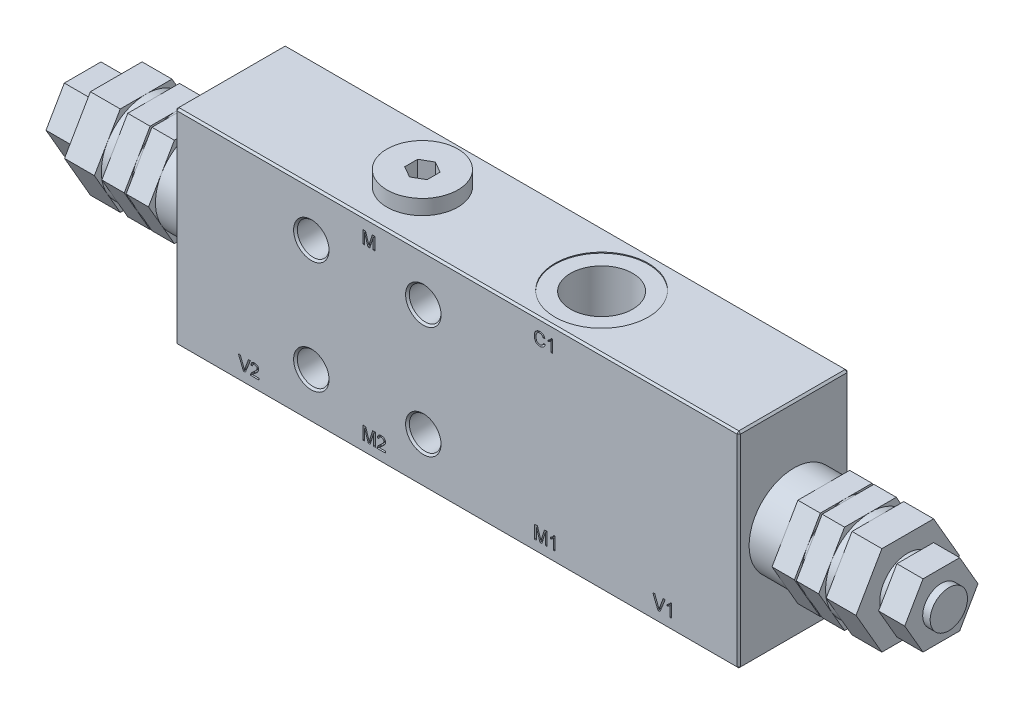
from build123d import *

# Parameters (mm, degrees)
SKETCH1_W            = 151
SKETCH1_H            = 55
SKETCH1_R            = 4.25
BASE_EXTRUDE_DEPTH   = 29.5
CHAMFER1_SIZE        = 0.5
SKETCH5_R            = 4.5
CUT_EXTRUDE4_DEPTH   = 20
HOLE1_D              = 16.662
HOLE1_DEPTH          = 20
HOLE1_CBORE_D        = 25
HOLE1_CBORE_DEPTH    = 0.25
SKETCH8_R            = 9.5
BOSS_EXTRUDE1_DEPTH  = 4
CUT_EXTRUDE5_DEPTH   = 10
HOLE2_D              = 16.662
HOLE2_DEPTH          = 20
HOLE2_CBORE_D        = 25
HOLE2_CBORE_DEPTH    = 0.25
LPATTERN1_COUNT      = 2
LPATTERN1_PITCH      = 111
SKETCH13_R           = 9.5
BOSS_EXTRUDE2_DEPTH  = 4
CUT_EXTRUDE6_DEPTH   = 10
SKETCH43_R           = 9.5
EXTRUDE1_DEPTH       = 4
CUT_EXTRUDE13_DEPTH  = 10
SKETCH15_R           = 12
BOSS_EXTRUDE3_DEPTH  = 8
BOSS_EXTRUDE4_DEPTH  = 6
SKETCH17_R           = 12
BOSS_EXTRUDE5_DEPTH  = 0.5
BOSS_EXTRUDE6_DEPTH  = 6
SKETCH19_R           = 12
BOSS_EXTRUDE7_DEPTH  = 2
BOSS_EXTRUDE8_DEPTH  = 8
SKETCH21_R           = 7.5
BOSS_EXTRUDE9_DEPTH  = 2
BOSS_EXTRUDE10_DEPTH = 7
SKETCH23_R           = 5
BOSS_EXTRUDE11_DEPTH = 2
SKETCH24_R           = 12
BOSS_EXTRUDE12_DEPTH = 8
BOSS_EXTRUDE13_DEPTH = 6
SKETCH26_R           = 12
BOSS_EXTRUDE14_DEPTH = 0.5
BOSS_EXTRUDE15_DEPTH = 6
SKETCH28_R           = 12
BOSS_EXTRUDE16_DEPTH = 2
BOSS_EXTRUDE17_DEPTH = 8
SKETCH30_R           = 7.5
BOSS_EXTRUDE18_DEPTH = 2
BOSS_EXTRUDE19_DEPTH = 7
SKETCH32_R           = 5
BOSS_EXTRUDE20_DEPTH = 2
CUT_EXTRUDE7_DEPTH   = 1
CUT_EXTRUDE8_DEPTH   = 1
CUT_EXTRUDE9_DEPTH   = 1
CUT_EXTRUDE10_DEPTH  = 1
CUT_EXTRUDE11_DEPTH  = 1
CUT_EXTRUDE12_DEPTH  = 1


with BuildPart() as part:
    # Sketch1 → Base-Extrude (new body)
    with BuildSketch(Plane.XY):
        with Locations((75.5, 27.5)):
            Rectangle(SKETCH1_W, SKETCH1_H)
        with Locations((36.5, 42.5)):
            Circle(SKETCH1_R, mode=Mode.SUBTRACT)
        with Locations((66.5, 42.5)):
            Circle(SKETCH1_R, mode=Mode.SUBTRACT)
        with Locations((36.5, 12.5)):
            Circle(SKETCH1_R, mode=Mode.SUBTRACT)
        with Locations((66.5, 12.5)):
            Circle(SKETCH1_R, mode=Mode.SUBTRACT)
    extrude(amount=-BASE_EXTRUDE_DEPTH)

    # Chamfer1
    chamfer1_edges = [part.edges().sort_by_distance(p)[0] for p in [
        (151, 27.5, -29.5),
        (32.25, 42.5, -29.5),
        (32.25, 42.5, 0),
        (75.5, 0, -29.5),
        (62.25, 42.5, -29.5),
        (62.25, 42.5, 0),
        (32.25, 12.5, -29.5),
        (32.25, 12.5, 0),
        (62.25, 12.5, -29.5),
        (62.25, 12.5, 0),
        (0, 27.5, -29.5),
        (75.5, 0, 0),
        (151, 27.5, 0),
        (75.5, 55, 0),
        (0, 27.5, 0),
        (75.5, 55, -29.5),
        (0, 0, -14.75),
        (151, 0, -14.75),
        (151, 55, -14.75),
        (0, 55, -14.75),
    ]]
    chamfer(chamfer1_edges, length=CHAMFER1_SIZE)

    # Sketch5 → Cut-Extrude4 (cut)
    with BuildSketch(Plane(origin=(0, 0, -29.5), x_dir=(-1, 0, 0), z_dir=(0, 0, -1))):
        with Locations((-51.5, 27.5)):
            Circle(SKETCH5_R)
    extrude(amount=-CUT_EXTRUDE4_DEPTH, mode=Mode.SUBTRACT)

    # Hole1
    with Locations(Plane(origin=(0, 55, 0), x_dir=(-1, 0, 0), z_dir=(0, 1, 0))):
        with Locations((-99.5, -14.75)):
            CounterBoreHole(HOLE1_D / 2, HOLE1_CBORE_D / 2, HOLE1_CBORE_DEPTH, depth=HOLE1_DEPTH)

    # Sketch8 → Boss-Extrude1 (add)
    with BuildSketch(Plane(origin=(0, 55, 0), x_dir=(-1, 0, 0), z_dir=(0, 1, 0))):
        with Locations((-51.5, -14.75)):
            Circle(SKETCH8_R)
    extrude(amount=BOSS_EXTRUDE1_DEPTH)

    # Sketch9 → Cut-Extrude5 (cut)
    with BuildSketch(Plane(origin=(0, 59, 0), x_dir=(-1, 0, 0), z_dir=(0, 1, 0))):
        Polygon((-51.5, -18.214101615), (-48.5, -16.482050808), (-48.5, -13.017949192), (-51.5, -11.285898385), (-54.5, -13.017949192), (-54.5, -16.482050808), align=None)
    extrude(amount=-CUT_EXTRUDE5_DEPTH, mode=Mode.SUBTRACT)

    # Hole2
    with Locations(Plane.XZ):
        with Locations((131, -14.75)):
            hole2 = CounterBoreHole(HOLE2_D / 2, HOLE2_CBORE_D / 2, HOLE2_CBORE_DEPTH, depth=HOLE2_DEPTH)

    # LPattern1: Hole2 ×2
    with Locations(*[(-i * LPATTERN1_PITCH, 0, 0) for i in range(1, LPATTERN1_COUNT)]):
        add(hole2, mode=Mode.SUBTRACT)

    # Sketch13 → Boss-Extrude2 (add)
    with BuildSketch(Plane.XZ):
        with Locations(Location((98, -14.75, 0), (0, 0, 270))):
            Circle(SKETCH13_R)
    extrude(amount=BOSS_EXTRUDE2_DEPTH)

    # Sketch14 → Cut-Extrude6 (cut)
    with BuildSketch(Plane.XZ.offset(4)):
        Polygon((98, -11.285898385), (95, -13.017949192), (95, -16.482050808), (98, -18.214101615), (101, -16.482050808), (101, -13.017949192), align=None)
    extrude(amount=-CUT_EXTRUDE6_DEPTH, mode=Mode.SUBTRACT)

    # Sketch43 → Extrude1 (add)
    with BuildSketch(Plane.XZ):
        with Locations(Location((52, -14.75, 0), (0, 0, 270))):
            Circle(SKETCH43_R)
    extrude(amount=EXTRUDE1_DEPTH)

    # Sketch44 → Cut-Extrude13 (cut)
    with BuildSketch(Plane.XZ.offset(4)):
        Polygon((49, -13.017949192), (49, -16.482050808), (52, -18.214101615), (55, -16.482050808), (55, -13.017949192), (52, -11.285898385), align=None)
    extrude(amount=-CUT_EXTRUDE13_DEPTH, mode=Mode.SUBTRACT)

    # Sketch15 → Boss-Extrude3 (add)
    with BuildSketch(Plane(origin=(151, 0, 0), x_dir=(0, 0, -1), z_dir=(1, 0, 0))):
        with Locations(Location((14.75, 27.5, 0), (0, 0, 180))):
            Circle(SKETCH15_R)
    extrude(amount=BOSS_EXTRUDE3_DEPTH)

    # Sketch16 → Boss-Extrude4 (add)
    with BuildSketch(Plane(origin=(159, 0, 0), x_dir=(0, 0, -1), z_dir=(1, 0, 0))):
        Polygon((21.67820323, 39.5), (7.82179677, 39.5), (0.893593539, 27.5), (7.82179677, 15.5), (21.67820323, 15.5), (28.606406461, 27.5), align=None)
    extrude(amount=BOSS_EXTRUDE4_DEPTH)

    # Sketch17 → Boss-Extrude5 (add)
    with BuildSketch(Plane(origin=(165, 0, 0), x_dir=(0, 0, -1), z_dir=(1, 0, 0))):
        with Locations(Location((14.75, 27.5, 0), (0, 0, 180))):
            Circle(SKETCH17_R)
    extrude(amount=BOSS_EXTRUDE5_DEPTH)

    # Sketch18 → Boss-Extrude6 (add)
    with BuildSketch(Plane(origin=(165.5, 0, 0), x_dir=(0, 0, -1), z_dir=(1, 0, 0))):
        Polygon((0.893593539, 27.5), (7.82179677, 15.5), (21.67820323, 15.5), (28.606406461, 27.5), (21.67820323, 39.5), (7.82179677, 39.5), align=None)
    extrude(amount=BOSS_EXTRUDE6_DEPTH)

    # Sketch19 → Boss-Extrude7 (add)
    with BuildSketch(Plane(origin=(171.5, 0, 0), x_dir=(0, 0, -1), z_dir=(1, 0, 0))):
        with Locations(Location((14.75, 27.5, 0), (0, 0, 180))):
            Circle(SKETCH19_R)
    extrude(amount=BOSS_EXTRUDE7_DEPTH)

    # Sketch20 → Boss-Extrude8 (add)
    with BuildSketch(Plane(origin=(173.5, 0, 0), x_dir=(0, 0, -1), z_dir=(1, 0, 0))):
        Polygon((0.893593539, 27.5), (7.82179677, 15.5), (21.67820323, 15.5), (28.606406461, 27.5), (21.67820323, 39.5), (7.82179677, 39.5), align=None)
    extrude(amount=BOSS_EXTRUDE8_DEPTH)

    # Sketch21 → Boss-Extrude9 (add)
    with BuildSketch(Plane(origin=(181.5, 0, 0), x_dir=(0, 0, -1), z_dir=(1, 0, 0))):
        with Locations(Location((14.75, 27.5, 0), (0, 0, 180))):
            Circle(SKETCH21_R)
    extrude(amount=BOSS_EXTRUDE9_DEPTH)

    # Sketch22 → Boss-Extrude10 (add)
    with BuildSketch(Plane(origin=(183.5, 0, 0), x_dir=(0, 0, -1), z_dir=(1, 0, 0))):
        Polygon((4.935045424, 27.5), (9.842522712, 19), (19.657477288, 19), (24.564954576, 27.5), (19.657477288, 36), (9.842522712, 36), align=None)
    extrude(amount=BOSS_EXTRUDE10_DEPTH)

    # Sketch23 → Boss-Extrude11 (add)
    with BuildSketch(Plane(origin=(190.5, 0, 0), x_dir=(0, 0, -1), z_dir=(1, 0, 0))):
        with Locations((14.75, 27.5)):
            Circle(SKETCH23_R)
    extrude(amount=BOSS_EXTRUDE11_DEPTH)

    # Sketch24 → Boss-Extrude12 (add)
    with BuildSketch(Plane.ZY):
        with Locations((-14.75, 27.5)):
            Circle(SKETCH24_R)
    extrude(amount=BOSS_EXTRUDE12_DEPTH)

    # Sketch25 → Boss-Extrude13 (add)
    with BuildSketch(Plane.ZY.offset(8)):
        Polygon((-0.893593539, 27.5), (-7.82179677, 39.5), (-21.67820323, 39.5), (-28.606406461, 27.5), (-21.67820323, 15.5), (-7.82179677, 15.5), align=None)
    extrude(amount=BOSS_EXTRUDE13_DEPTH)

    # Sketch26 → Boss-Extrude14 (add)
    with BuildSketch(Plane.ZY.offset(14)):
        with Locations((-14.75, 27.5)):
            Circle(SKETCH26_R)
    extrude(amount=BOSS_EXTRUDE14_DEPTH)

    # Sketch27 → Boss-Extrude15 (add)
    with BuildSketch(Plane.ZY.offset(14.5)):
        Polygon((-0.893593539, 27.5), (-7.82179677, 39.5), (-21.67820323, 39.5), (-28.606406461, 27.5), (-21.67820323, 15.5), (-7.82179677, 15.5), align=None)
    extrude(amount=BOSS_EXTRUDE15_DEPTH)

    # Sketch28 → Boss-Extrude16 (add)
    with BuildSketch(Plane.ZY.offset(20.5)):
        with Locations((-14.75, 27.5)):
            Circle(SKETCH28_R)
    extrude(amount=BOSS_EXTRUDE16_DEPTH)

    # Sketch29 → Boss-Extrude17 (add)
    with BuildSketch(Plane.ZY.offset(22.5)):
        Polygon((-0.893593539, 27.5), (-7.82179677, 39.5), (-21.67820323, 39.5), (-28.606406461, 27.5), (-21.67820323, 15.5), (-7.82179677, 15.5), align=None)
    extrude(amount=BOSS_EXTRUDE17_DEPTH)

    # Sketch30 → Boss-Extrude18 (add)
    with BuildSketch(Plane.ZY.offset(30.5)):
        with Locations((-14.75, 27.5)):
            Circle(SKETCH30_R)
    extrude(amount=BOSS_EXTRUDE18_DEPTH)

    # Sketch31 → Boss-Extrude19 (add)
    with BuildSketch(Plane.ZY.offset(32.5)):
        Polygon((-4.935045424, 27.5), (-9.842522712, 36), (-19.657477288, 36), (-24.564954576, 27.5), (-19.657477288, 19), (-9.842522712, 19), align=None)
    extrude(amount=BOSS_EXTRUDE19_DEPTH)

    # Sketch32 → Boss-Extrude20 (add)
    with BuildSketch(Plane.ZY.offset(39.5)):
        with Locations(Location((-14.75, 27.5, 0), (0, 0, 180))):
            Circle(SKETCH32_R)
    extrude(amount=BOSS_EXTRUDE20_DEPTH)

    # Sketch33 → Cut-Extrude7 (cut)
    with BuildSketch(Plane.XY):
        with BuildLine():
            Line((129.353624939, 3), (127.959128008, 6.458186129))
            Line((127.959128008, 6.458186129), (128.487692916, 6.458186129))
            Line((128.487692916, 6.458186129), (129.428441466, 3.979542305))
            add(Edge.make_bspline(
                [(129.428441466, 3.979542305), (129.446850982, 3.930649992), (129.482863794, 3.835006544), (129.533083688, 3.693078224), (129.57797725, 3.555826305), (129.60504301, 3.465350458), (129.618253765, 3.421189336)],
                knots=[0, 0, 0, 0, 1.062747156, 2.078952616, 3.062339733, 4, 4, 4, 4], degree=3))
            add(Edge.make_bspline(
                [(129.618253765, 3.421189336), (129.646377518, 3.514574668), (129.703028249, 3.702684252), (129.7715055, 3.88681941), (129.805987828, 3.979542305)],
                knots=[0, 0, 0, 0, 0.992882236, 2, 2, 2, 2], degree=3))
            Line((129.805987828, 3.979542305), (130.748814615, 6.458186129))
            Line((130.748814615, 6.458186129), (131.277379522, 6.458186129))
            Line((131.277379522, 6.458186129), (129.882189846, 3))
            Line((129.882189846, 3), (129.353624939, 3))
        make_face()
        with BuildLine():
            Line((132.965600595, 3), (132.522243399, 3))
            Line((132.522243399, 3), (132.522243399, 5.694780457))
            add(Edge.make_bspline(
                [(132.522243399, 5.694780457), (132.496714852, 5.670161314), (132.443656566, 5.618993125), (132.353967138, 5.54657736), (132.253862274, 5.473180912), (132.1446419, 5.402602023), (132.033310205, 5.336159609), (131.925722455, 5.276404874), (131.823674874, 5.225837869), (131.756455581, 5.198187631), (131.724200446, 5.184919681)],
                knots=[0, 0, 0, 0, 0.893362401, 1.856755847, 2.901947673, 4.020460078, 5.132200827, 6.168787962, 7.121294059, 8, 8, 8, 8], degree=3))
            Line((131.724200446, 5.184919681), (131.724200446, 5.593639596))
            add(Edge.make_bspline(
                [(131.724200446, 5.593639596), (131.779601974, 5.622171494), (131.888795105, 5.678406175), (132.043061388, 5.775531201), (132.187085558, 5.880818726), (132.318483444, 5.994245441), (132.436273276, 6.110187905), (132.535536478, 6.227178406), (132.618593609, 6.340928576), (132.660264945, 6.420256706), (132.6801894, 6.458186129)],
                knots=[0, 0, 0, 0, 1.141258006, 2.249351951, 3.335817539, 4.406819942, 5.426913362, 6.360259544, 7.215985427, 8, 8, 8, 8], degree=3))
            Line((132.6801894, 6.458186129), (132.965600595, 6.458186129))
            Line((132.965600595, 6.458186129), (132.965600595, 3))
        make_face()
    extrude(amount=-CUT_EXTRUDE7_DEPTH, mode=Mode.SUBTRACT)

    # Sketch34 → Cut-Extrude8 (cut)
    with BuildSketch(Plane.XY):
        with BuildLine():
            Line((18.31643864, 3), (16.960250829, 6.36318408))
            Line((16.960250829, 6.36318408), (17.474295191, 6.36318408))
            Line((17.474295191, 6.36318408), (18.389199834, 3.95263267))
            add(Edge.make_bspline(
                [(18.389199834, 3.95263267), (18.407103611, 3.905083509), (18.442127091, 3.812067544), (18.490967363, 3.674038228), (18.534627625, 3.540556844), (18.560949844, 3.452566517), (18.573797678, 3.409618574)],
                knots=[0, 0, 0, 0, 1.062747156, 2.078952616, 3.062339733, 4, 4, 4, 4], degree=3))
            add(Edge.make_bspline(
                [(18.573797678, 3.409618574), (18.601148825, 3.500438458), (18.656243268, 3.683380363), (18.722839336, 3.862457026), (18.756374378, 3.95263267)],
                knots=[0, 0, 0, 0, 0.992882236, 2, 2, 2, 2], degree=3))
            Line((18.756374378, 3.95263267), (19.673300166, 6.36318408))
            Line((19.673300166, 6.36318408), (20.187344527, 6.36318408))
            Line((20.187344527, 6.36318408), (18.830483002, 3))
            Line((18.830483002, 3), (18.31643864, 3))
        make_face()
        with BuildLine():
            Line((22.432835821, 3.431177446), (22.432835821, 3))
            Line((22.432835821, 3), (20.233830846, 3))
            add(Edge.make_bspline(
                [(20.233830846, 3), (20.233785826, 3.025626088), (20.233695938, 3.076792371), (20.242354098, 3.152464057), (20.255914509, 3.227131895), (20.27124726, 3.27501341), (20.278969735, 3.299129353)],
                knots=[0, 0, 0, 0, 1.01057331, 2.01775941, 3.001627217, 4, 4, 4, 4], degree=3))
            add(Edge.make_bspline(
                [(20.278969735, 3.299129353), (20.293238298, 3.338531927), (20.322291443, 3.418762057), (20.381153419, 3.534522931), (20.450389012, 3.649583705), (20.517799608, 3.743259421), (20.579533158, 3.818099769), (20.631304786, 3.876653679), (20.68867724, 3.936590507), (20.751604575, 3.997899303), (20.819481151, 4.060977141), (20.892399588, 4.126034381), (20.971220936, 4.191858612), (21.026246486, 4.23548965), (21.054415423, 4.257825456)],
                knots=[0, 0, 0, 0, 1.204657718, 2.452881516, 3.728232997, 5.065887527, 5.768225529, 6.518857853, 7.313994055, 8.154655305, 9.046094665, 9.979688118, 10.965752482, 12, 12, 12, 12], degree=3))
            add(Edge.make_bspline(
                [(21.054415423, 4.257825456), (21.097689869, 4.294248854), (21.181017558, 4.364384418), (21.298689315, 4.468459095), (21.40616331, 4.565098327), (21.501728143, 4.655995915), (21.586165434, 4.740270211), (21.659673443, 4.817730281), (21.722884656, 4.888134386), (21.775027387, 4.954030859), (21.81902181, 5.016255458), (21.856303197, 5.076951712), (21.887372287, 5.137179851), (21.913248682, 5.196749297), (21.933714711, 5.255914796), (21.947665222, 5.314848723), (21.957125975, 5.372966311), (21.958072531, 5.411638399), (21.95854063, 5.430762852)],
                knots=[0, 0, 0, 0, 1.782554561, 3.432421876, 4.950675607, 6.337395053, 7.588547463, 8.709982106, 9.702713005, 10.569305638, 11.356701089, 12.103210377, 12.812277205, 13.490692607, 14.148717897, 14.782152033, 15.397739362, 16, 16, 16, 16], degree=3))
            add(Edge.make_bspline(
                [(21.95854063, 5.430762852), (21.958072475, 5.449664166), (21.95715398, 5.486747515), (21.948439341, 5.541018765), (21.936307866, 5.593283276), (21.916694964, 5.642600171), (21.893349705, 5.690429916), (21.863403776, 5.735261151), (21.828762492, 5.778211187), (21.789101154, 5.818147632), (21.745781684, 5.855614393), (21.69737835, 5.886758373), (21.64707027, 5.914797235), (21.593121857, 5.937342088), (21.535620774, 5.953897176), (21.474985601, 5.965911906), (21.411225962, 5.973529889), (21.36771449, 5.974584823), (21.345460199, 5.975124378)],
                knots=[0, 0, 0, 0, 0.988194508, 1.938783882, 2.870742509, 3.789494954, 4.709148727, 5.651055405, 6.603531303, 7.592354411, 8.592907906, 9.593461401, 10.59787167, 11.603930315, 12.645063138, 13.723588815, 14.835711238, 16, 16, 16, 16], degree=3))
            add(Edge.make_bspline(
                [(21.345460199, 5.975124378), (21.322082685, 5.974587496), (21.276331171, 5.973536777), (21.209454711, 5.965888412), (21.145967104, 5.954202745), (21.086019885, 5.936336359), (21.029686019, 5.913829101), (20.97719494, 5.885498457), (20.927706047, 5.853518284), (20.882777937, 5.815656171), (20.842150036, 5.773674812), (20.806081919, 5.72796981), (20.776529516, 5.677659155), (20.752123923, 5.623849066), (20.732499783, 5.566370382), (20.718253325, 5.504783693), (20.710486061, 5.439266819), (20.708924129, 5.394400883), (20.708126036, 5.371475954)],
                knots=[0, 0, 0, 0, 1.131143733, 2.213731411, 3.253917892, 4.251203413, 5.236093891, 6.184197493, 7.13373276, 8.082770301, 9.020476205, 9.957489029, 10.893177274, 11.836722509, 12.812818608, 13.827831385, 14.890097571, 16, 16, 16, 16], degree=3))
            Line((20.708126036, 5.371475954), (20.27694859, 5.414593698))
            add(Edge.make_bspline(
                [(20.27694859, 5.414593698), (20.281360148, 5.452171866), (20.289942454, 5.525276958), (20.311319808, 5.631157369), (20.341331677, 5.729656501), (20.377243412, 5.82214764), (20.422262155, 5.907056308), (20.47315197, 5.986138745), (20.533174158, 6.056886788), (20.599482751, 6.121530516), (20.672804233, 6.178498651), (20.752449861, 6.228268225), (20.838383203, 6.269897401), (20.930125641, 6.304364624), (21.027887792, 6.330515773), (21.131531356, 6.349268614), (21.24122301, 6.36082808), (21.31646185, 6.362387541), (21.354892206, 6.36318408)],
                knots=[0, 0, 0, 0, 1.130804643, 2.199883102, 3.223565206, 4.205909148, 5.160801384, 6.091796021, 7.01151579, 7.927798993, 8.855738875, 9.7815393, 10.730299821, 11.705391175, 12.706931101, 13.751121791, 14.851322166, 16, 16, 16, 16], degree=3))
            add(Edge.make_bspline(
                [(21.354892206, 6.36318408), (21.393782551, 6.362518127), (21.469541173, 6.361220846), (21.579933661, 6.347947062), (21.684092026, 6.327273264), (21.782398107, 6.29846032), (21.874271099, 6.260677958), (21.959781674, 6.214516443), (22.039324103, 6.160426067), (22.111569395, 6.097757511), (22.176714864, 6.029344284), (22.233805261, 5.956332623), (22.281535582, 5.879034435), (22.322174986, 5.798503348), (22.352318732, 5.713037792), (22.37351637, 5.623799688), (22.387920779, 5.530712779), (22.389111013, 5.467199368), (22.389718076, 5.434805141)],
                knots=[0, 0, 0, 0, 1.195390245, 2.328627238, 3.413424916, 4.457841177, 5.473507151, 6.462241215, 7.441013641, 8.425227782, 9.397253344, 10.342087291, 11.269524934, 12.186751184, 13.110685745, 14.048630397, 15.004728144, 16, 16, 16, 16], degree=3))
            add(Edge.make_bspline(
                [(22.389718076, 5.434805141), (22.3887911, 5.401523743), (22.386935102, 5.334887501), (22.372448787, 5.235285971), (22.347662541, 5.136765339), (22.314802594, 5.038126551), (22.269909068, 4.938978112), (22.213193721, 4.837952268), (22.142832135, 4.734675838), (22.075164017, 4.646879398), (22.012175982, 4.573283842), (21.956343041, 4.512710399), (21.89174756, 4.448355167), (21.820812757, 4.377989374), (21.74064557, 4.304110451), (21.653549388, 4.22450605), (21.557617635, 4.141271055), (21.491022302, 4.084408902), (21.456623134, 4.055037313)],
                knots=[0, 0, 0, 0, 0.927118007, 1.856282007, 2.79721255, 3.754929441, 4.749232485, 5.824981375, 6.979078785, 8.228161913, 8.911614355, 9.677694854, 10.522803217, 11.452009355, 12.461436787, 13.560019032, 14.739651695, 16, 16, 16, 16], degree=3))
            add(Edge.make_bspline(
                [(21.456623134, 4.055037313), (21.427165443, 4.031055612), (21.370994159, 3.9853262), (21.291079627, 3.919031045), (21.219500513, 3.858240185), (21.15458295, 3.804936501), (21.098691194, 3.756541762), (21.049856536, 3.715175445), (21.009853166, 3.678757667), (20.948935116, 3.623438328), (20.871777209, 3.544586202), (20.814923962, 3.467967793), (20.787624378, 3.431177446)],
                knots=[0, 0, 0, 0, 1.241996727, 2.368296581, 3.394949853, 4.3125351, 5.114548721, 5.812230366, 6.404953749, 6.883082049, 8.503329734, 10, 10, 10, 10], degree=3))
            Line((20.787624378, 3.431177446), (22.432835821, 3.431177446))
        make_face()
    extrude(amount=-CUT_EXTRUDE8_DEPTH, mode=Mode.SUBTRACT)

    # Sketch35 → Cut-Extrude9 (cut)
    with BuildSketch(Plane.XY):
        with BuildLine():
            Line((98.673300166, 49.687085406), (99.147595357, 49.576596186))
            add(Edge.make_bspline(
                [(99.147595357, 49.576596186), (99.135712938, 49.532141815), (99.112469453, 49.445183549), (99.066514259, 49.320736644), (99.014935189, 49.203948532), (98.956480703, 49.095126853), (98.89051102, 48.994897265), (98.818774071, 48.901971625), (98.738428457, 48.81829867), (98.652422153, 48.741947272), (98.560085508, 48.674605544), (98.462531784, 48.616454726), (98.360232535, 48.566980183), (98.2527743, 48.526295358), (98.140087413, 48.495676538), (98.022752099, 48.473359749), (97.900426218, 48.459613906), (97.817044703, 48.457804226), (97.774564677, 48.456882255)],
                knots=[0, 0, 0, 0, 1.145254194, 2.240259345, 3.299159039, 4.322497661, 5.312016644, 6.284080175, 7.241264552, 8.196044782, 9.144516039, 10.082428046, 11.020306713, 11.970622414, 12.939253955, 13.924100776, 14.94240044, 16, 16, 16, 16], degree=3))
            add(Edge.make_bspline(
                [(97.774564677, 48.456882255), (97.730979347, 48.457515472), (97.645708132, 48.45875431), (97.520790718, 48.468830686), (97.401981992, 48.486306592), (97.289503825, 48.510586863), (97.182977629, 48.540607909), (97.08284514, 48.578377044), (96.989281743, 48.623621752), (96.901506995, 48.675076677), (96.819893705, 48.733531789), (96.742585959, 48.797409544), (96.671460531, 48.868468425), (96.604739018, 48.945030666), (96.543874637, 49.028106229), (96.486628174, 49.116566499), (96.435793798, 49.211970141), (96.389487624, 49.31254837), (96.348843706, 49.417327407), (96.312888055, 49.524237577), (96.283492344, 49.63349191), (96.258184535, 49.74417105), (96.239799637, 49.857206286), (96.225202598, 49.971749507), (96.217176852, 50.088502963), (96.216120748, 50.166983784), (96.215588723, 50.206519486)],
                knots=[0, 0, 0, 0, 1.180702053, 2.309949215, 3.392367133, 4.431746864, 5.425408375, 6.388154007, 7.326956194, 8.237882283, 9.141054626, 10.043899035, 10.951650021, 11.86168169, 12.792564695, 13.739356664, 14.713891418, 15.718426911, 16.737522708, 17.757217648, 18.772674716, 19.801476837, 20.831699174, 21.873853055, 22.928926693, 24, 24, 24, 24], degree=3))
            add(Edge.make_bspline(
                [(96.215588723, 50.206519486), (96.216349631, 50.249199871), (96.217852994, 50.333525531), (96.226339453, 50.45795049), (96.241926003, 50.578035798), (96.263571186, 50.693860443), (96.290961002, 50.805518226), (96.32477066, 50.913063548), (96.364572469, 51.016358804), (96.410245087, 51.115517899), (96.462091953, 51.209433956), (96.518565653, 51.298240484), (96.581013299, 51.380479318), (96.647583413, 51.457721656), (96.719938628, 51.528681324), (96.797858002, 51.593519064), (96.88066928, 51.652826278), (96.968360376, 51.706052381), (97.059785064, 51.752755502), (97.153585393, 51.794354379), (97.250134447, 51.828450313), (97.348666759, 51.856799712), (97.449394458, 51.879368466), (97.552552907, 51.894460263), (97.658046786, 51.904295247), (97.729178997, 51.905628124), (97.76513267, 51.906301824)],
                knots=[0, 0, 0, 0, 1.185634383, 2.342514083, 3.462112933, 4.547331452, 5.613960142, 6.653690668, 7.676612054, 8.686959706, 9.683658101, 10.654407272, 11.607580201, 12.5494388, 13.484601218, 14.419076806, 15.362504069, 16.311442244, 17.265594461, 18.212500624, 19.159571152, 20.107257795, 21.059246075, 22.024387127, 23.001429356, 24, 24, 24, 24], degree=3))
            add(Edge.make_bspline(
                [(97.76513267, 51.906301824), (97.805359986, 51.905543559), (97.884430759, 51.904053114), (98.000453031, 51.891793911), (98.111572074, 51.871261087), (98.218269388, 51.844323965), (98.319435661, 51.807441437), (98.416169227, 51.76359235), (98.507507778, 51.710912984), (98.594162008, 51.650851063), (98.674721317, 51.583295818), (98.750313047, 51.509861126), (98.817854966, 51.428711656), (98.880022144, 51.341811369), (98.934858593, 51.247955254), (98.984381692, 51.147961637), (99.026970115, 51.041087179), (99.049757043, 50.966646162), (99.061359867, 50.928741708)],
                knots=[0, 0, 0, 0, 1.098391872, 2.158997981, 3.181470371, 4.182549255, 5.160268219, 6.118029851, 7.079534476, 8.035645336, 8.993622929, 9.94770573, 10.909620999, 11.872786677, 12.862530088, 13.874594564, 14.917769567, 16, 16, 16, 16], degree=3))
            Line((99.061359867, 50.928741708), (98.587064677, 50.827010779))
            add(Edge.make_bspline(
                [(98.587064677, 50.827010779), (98.577750259, 50.856100502), (98.559519063, 50.91303809), (98.52714779, 50.994184271), (98.492187895, 51.06951444), (98.453806604, 51.138516535), (98.411920736, 51.201207083), (98.367494813, 51.258347997), (98.319464433, 51.308872731), (98.268806574, 51.353946261), (98.214213103, 51.392344596), (98.156963926, 51.426371839), (98.095851946, 51.454524194), (98.031756303, 51.47833527), (97.964077903, 51.496458065), (97.893092341, 51.509208166), (97.818737247, 51.5165873), (97.768068426, 51.517683195), (97.742226368, 51.518242123)],
                knots=[0, 0, 0, 0, 1.235697765, 2.418642872, 3.532555292, 4.594392283, 5.610119701, 6.580908344, 7.519430642, 8.427315627, 9.319973334, 10.216139639, 11.118687699, 12.038725643, 12.980015607, 13.949697744, 14.954307006, 16, 16, 16, 16], degree=3))
            add(Edge.make_bspline(
                [(97.742226368, 51.518242123), (97.712557321, 51.517811654), (97.654207061, 51.51696505), (97.56848351, 51.50769906), (97.486159084, 51.49405116), (97.407847346, 51.473584961), (97.333119768, 51.448068934), (97.262419796, 51.416296965), (97.195146025, 51.37905649), (97.132049265, 51.336123876), (97.073659786, 51.287859356), (97.018393067, 51.236836206), (96.968902524, 51.180674824), (96.923300935, 51.121227073), (96.882916215, 51.057442468), (96.846563202, 50.990189832), (96.814473619, 50.918917977), (96.779493795, 50.81860824), (96.743827175, 50.689411619), (96.712886339, 50.531316829), (96.693177755, 50.370731267), (96.690984182, 50.262718491), (96.689883914, 50.20854063)],
                knots=[0, 0, 0, 0, 0.935256702, 1.839373932, 2.716087708, 3.564631604, 4.388828665, 5.203538865, 6.005592122, 6.810952829, 7.606223804, 8.392839071, 9.180346482, 9.963639178, 10.753404291, 11.558266631, 12.372976832, 13.215232055, 14.905983541, 16.594894834, 18.292041732, 20, 20, 20, 20], degree=3))
            add(Edge.make_bspline(
                [(96.689883914, 50.20854063), (96.691124861, 50.140421037), (96.69353241, 50.008262857), (96.717289005, 49.816743825), (96.753509193, 49.638108119), (96.79722174, 49.498736675), (96.841069818, 49.395933674), (96.87653194, 49.32393925), (96.917010537, 49.257319103), (96.96149876, 49.195694888), (97.010569663, 49.139246362), (97.063539589, 49.087673666), (97.12042037, 49.04048055), (97.181885991, 48.999876209), (97.245570563, 48.963823095), (97.310670438, 48.931763977), (97.377226602, 48.904649794), (97.445507584, 48.883586946), (97.514554533, 48.865385717), (97.585127933, 48.85349582), (97.657207657, 48.846785537), (97.70560741, 48.845561411), (97.730099502, 48.844941957)],
                knots=[0, 0, 0, 0, 2.10686522, 4.087509323, 5.961373225, 7.741398778, 8.594514555, 9.418024779, 10.222433421, 11.003575649, 11.767087398, 12.533660211, 13.289033706, 14.050297079, 14.809623433, 15.552362432, 16.294320901, 17.0305302, 17.761969017, 18.502233515, 19.242073914, 20, 20, 20, 20], degree=3))
            add(Edge.make_bspline(
                [(97.730099502, 48.844941957), (97.759327461, 48.845554929), (97.817063014, 48.846765765), (97.901710666, 48.85736428), (97.983309835, 48.872982579), (98.06087196, 48.897083191), (98.135440337, 48.926591567), (98.206404008, 48.962980556), (98.273539803, 49.006745888), (98.337637385, 49.056437312), (98.397514739, 49.112977661), (98.452389116, 49.175911418), (98.501617631, 49.24552549), (98.547264853, 49.320702671), (98.585616909, 49.403688783), (98.621139968, 49.492010374), (98.650740347, 49.587119088), (98.665672201, 49.653284624), (98.673300166, 49.687085406)],
                knots=[0, 0, 0, 0, 1.013374089, 2.001772144, 2.95501459, 3.891367103, 4.814208647, 5.733921849, 6.652182523, 7.590185968, 8.54346024, 9.504121027, 10.481158517, 11.497760682, 12.549996529, 13.647863555, 14.798406869, 16, 16, 16, 16], degree=3))
        make_face()
        with BuildLine():
            Line((101.087893864, 48.5), (100.656716418, 48.5))
            Line((100.656716418, 48.5), (100.656716418, 51.120750415))
            add(Edge.make_bspline(
                [(100.656716418, 51.120750415), (100.631889182, 51.096807601), (100.580288494, 51.047045085), (100.493062982, 50.9766187), (100.395708163, 50.905238573), (100.289488252, 50.836598602), (100.181215021, 50.771981471), (100.076582884, 50.713868295), (99.977338717, 50.664690449), (99.911966049, 50.637799809), (99.880597015, 50.624896352)],
                knots=[0, 0, 0, 0, 0.893362401, 1.856755847, 2.901947673, 4.020460078, 5.132200827, 6.168787962, 7.121294059, 8, 8, 8, 8], degree=3))
            Line((99.880597015, 50.624896352), (99.880597015, 51.02238806))
            add(Edge.make_bspline(
                [(99.880597015, 51.02238806), (99.934476572, 51.05013614), (100.040669989, 51.104825962), (100.190698324, 51.199282803), (100.330765913, 51.301677907), (100.458554083, 51.411988604), (100.573108035, 51.524745939), (100.669644314, 51.638522518), (100.75041973, 51.749147785), (100.790946286, 51.82629664), (100.810323383, 51.86318408)],
                knots=[0, 0, 0, 0, 1.141258006, 2.249351951, 3.335817539, 4.406819942, 5.426913362, 6.360259544, 7.215985427, 8, 8, 8, 8], degree=3))
            Line((100.810323383, 51.86318408), (101.087893864, 51.86318408))
            Line((101.087893864, 51.86318408), (101.087893864, 48.5))
        make_face()
    extrude(amount=-CUT_EXTRUDE9_DEPTH, mode=Mode.SUBTRACT)

    # Sketch36 → Cut-Extrude10 (cut)
    with BuildSketch(Plane.XY):
        with BuildLine():
            Line((50.301824212, 48.5), (50.301824212, 51.86318408))
            Line((50.301824212, 51.86318408), (51.015288143, 51.86318408))
            Line((51.015288143, 51.86318408), (51.767153814, 49.503161277))
            add(Edge.make_bspline(
                [(51.767153814, 49.503161277), (51.775428128, 49.476426332), (51.791430169, 49.424722503), (51.815159297, 49.350057418), (51.836748826, 49.280672957), (51.856193596, 49.216348267), (51.874543877, 49.157402716), (51.890432329, 49.103352613), (51.905622206, 49.054798574), (51.914524152, 49.023940895), (51.918739635, 49.009328358)],
                knots=[0, 0, 0, 0, 1.300204174, 2.514519184, 3.639827924, 4.676153899, 5.636536826, 6.507959918, 7.293450077, 8, 8, 8, 8], degree=3))
            add(Edge.make_bspline(
                [(51.918739635, 49.009328358), (51.923434704, 49.02527922), (51.933426112, 49.059223674), (51.949623781, 49.112595509), (51.966858562, 49.17165745), (51.987483312, 49.235394319), (52.008982172, 49.304805947), (52.031548025, 49.37983469), (52.057577296, 49.459731476), (52.074875048, 49.515045249), (52.083799751, 49.543584163)],
                knots=[0, 0, 0, 0, 0.713638162, 1.518667645, 2.393860736, 3.354087503, 4.393659122, 5.512594909, 6.716633584, 8, 8, 8, 8], degree=3))
            Line((52.083799751, 49.543584163), (52.828254561, 51.86318408))
            Line((52.828254561, 51.86318408), (53.535655058, 51.86318408))
            Line((53.535655058, 51.86318408), (53.535655058, 48.5))
            Line((53.535655058, 48.5), (53.061359867, 48.5))
            Line((53.061359867, 48.5), (53.061359867, 51.345771144))
            Line((53.061359867, 51.345771144), (52.163971808, 48.5))
            Line((52.163971808, 48.5), (51.668117745, 48.5))
            Line((51.668117745, 48.5), (50.776119403, 51.345771144))
            Line((50.776119403, 51.345771144), (50.776119403, 48.5))
            Line((50.776119403, 48.5), (50.301824212, 48.5))
        make_face()
    extrude(amount=-CUT_EXTRUDE10_DEPTH, mode=Mode.SUBTRACT)

    # Sketch37 → Cut-Extrude11 (cut)
    with BuildSketch(Plane.XY):
        with BuildLine():
            Line((50.314102564, 3), (50.314102564, 6.5))
            Line((50.314102564, 6.5), (51.056590545, 6.5))
            Line((51.056590545, 6.5), (51.839042468, 4.043970353))
            add(Edge.make_bspline(
                [(51.839042468, 4.043970353), (51.847653385, 4.016147817), (51.864306396, 3.962340652), (51.889000837, 3.884638156), (51.911468638, 3.812431102), (51.93170443, 3.745489653), (51.950801209, 3.684146169), (51.967336011, 3.627897283), (51.983143819, 3.577368043), (51.992407901, 3.545255059), (51.996794872, 3.530048077)],
                knots=[0, 0, 0, 0, 1.300204174, 2.514519184, 3.639827924, 4.676153899, 5.636536826, 6.507959918, 7.293450077, 8, 8, 8, 8], degree=3))
            add(Edge.make_bspline(
                [(51.996794872, 3.530048077), (52.001680939, 3.546647827), (52.012078801, 3.581973158), (52.028935399, 3.637516184), (52.046871299, 3.698980793), (52.068335073, 3.765310508), (52.090708518, 3.837545834), (52.11419236, 3.915626782), (52.141280514, 3.998773807), (52.159281947, 4.05633777), (52.168569712, 4.08603766)],
                knots=[0, 0, 0, 0, 0.713638162, 1.518667645, 2.393860736, 3.354087503, 4.393659122, 5.512594909, 6.716633584, 8, 8, 8, 8], degree=3))
            Line((52.168569712, 4.08603766), (52.943309295, 6.5))
            Line((52.943309295, 6.5), (53.679487179, 6.5))
            Line((53.679487179, 6.5), (53.679487179, 3))
            Line((53.679487179, 3), (53.185897436, 3))
            Line((53.185897436, 3), (53.185897436, 5.961538462))
            Line((53.185897436, 5.961538462), (52.252003205, 3))
            Line((52.252003205, 3), (51.735977564, 3))
            Line((51.735977564, 3), (50.807692308, 5.961538462))
            Line((50.807692308, 5.961538462), (50.807692308, 3))
            Line((50.807692308, 3), (50.314102564, 3))
        make_face()
        with BuildLine():
            Line((56.416666667, 3.448717949), (56.416666667, 3))
            Line((56.416666667, 3), (54.128205128, 3))
            add(Edge.make_bspline(
                [(54.128205128, 3), (54.128158277, 3.026668569), (54.128064733, 3.079916321), (54.13707511, 3.158666367), (54.151187165, 3.236371728), (54.16714366, 3.286201086), (54.175180288, 3.311298077)],
                knots=[0, 0, 0, 0, 1.01057331, 2.01775941, 3.001627217, 4, 4, 4, 4], degree=3))
            add(Edge.make_bspline(
                [(54.175180288, 3.311298077), (54.190029304, 3.352303566), (54.220264344, 3.435797496), (54.281520853, 3.556267577), (54.353572983, 3.676009078), (54.423725875, 3.773495566), (54.487970774, 3.851380454), (54.541848496, 3.912316366), (54.601554889, 3.974691452), (54.667042138, 4.03849432), (54.737679966, 4.104138193), (54.813564758, 4.171841993), (54.895592596, 4.240343984), (54.952856611, 4.285749954), (54.982171474, 4.308994391)],
                knots=[0, 0, 0, 0, 1.204657718, 2.452881516, 3.728232997, 5.065887527, 5.768225529, 6.518857853, 7.313994055, 8.154655305, 9.046094665, 9.979688118, 10.965752482, 12, 12, 12, 12], degree=3))
            add(Edge.make_bspline(
                [(54.982171474, 4.308994391), (55.027206345, 4.34689951), (55.113923845, 4.419888222), (55.236382544, 4.528196706), (55.348228632, 4.628767268), (55.447681088, 4.723362613), (55.535553328, 4.811065227), (55.612051677, 4.891676409), (55.677834352, 4.964944587), (55.732098274, 5.033521759), (55.777882411, 5.098277684), (55.816680423, 5.161443091), (55.849013418, 5.224121339), (55.875942477, 5.286114098), (55.897241074, 5.347686478), (55.911759098, 5.409017865), (55.921604719, 5.469499704), (55.922589782, 5.509744991), (55.923076923, 5.529647436)],
                knots=[0, 0, 0, 0, 1.782554561, 3.432421876, 4.950675607, 6.337395053, 7.588547463, 8.709982106, 9.702713005, 10.569305638, 11.356701089, 12.103210377, 12.812277205, 13.490692607, 14.148717897, 14.782152033, 15.397739362, 16, 16, 16, 16], degree=3))
            add(Edge.make_bspline(
                [(55.923076923, 5.529647436), (55.922589723, 5.549317664), (55.921633863, 5.587909581), (55.912564709, 5.644388611), (55.89993972, 5.698779267), (55.879528955, 5.750102397), (55.855234, 5.799877878), (55.824069856, 5.84653287), (55.788019349, 5.891230133), (55.746744568, 5.932791211), (55.701662842, 5.971782138), (55.651290438, 6.00419307), (55.598935801, 6.033372566), (55.542792741, 6.056834554), (55.482952486, 6.074063111), (55.419850647, 6.086566606), (55.353497235, 6.094494492), (55.308215696, 6.095592342), (55.28505609, 6.096153846)],
                knots=[0, 0, 0, 0, 0.988194508, 1.938783882, 2.870742509, 3.789494954, 4.709148727, 5.651055405, 6.603531303, 7.592354411, 8.592907906, 9.593461401, 10.59787167, 11.603930315, 12.645063138, 13.723588815, 14.835711238, 16, 16, 16, 16], degree=3))
            add(Edge.make_bspline(
                [(55.28505609, 6.096153846), (55.260727567, 6.095595123), (55.21311486, 6.094501661), (55.143517834, 6.086542157), (55.077447521, 6.074381111), (55.015061621, 6.055787912), (54.956436067, 6.032365048), (54.901809625, 6.0028819), (54.850307501, 5.969600758), (54.803551694, 5.930198397), (54.761271031, 5.886509216), (54.723735646, 5.838944913), (54.692981037, 5.786587597), (54.667582613, 5.730588488), (54.647160154, 5.670771544), (54.632334143, 5.606679479), (54.624250903, 5.538497348), (54.622625431, 5.491806244), (54.621794872, 5.467948718)],
                knots=[0, 0, 0, 0, 1.131143733, 2.213731411, 3.253917892, 4.251203413, 5.236093891, 6.184197493, 7.13373276, 8.082770301, 9.020476205, 9.957489029, 10.893177274, 11.836722509, 12.812818608, 13.827831385, 14.890097571, 16, 16, 16, 16], degree=3))
            Line((54.621794872, 5.467948718), (54.173076923, 5.512820513))
            add(Edge.make_bspline(
                [(54.173076923, 5.512820513), (54.177667945, 5.551927378), (54.186599383, 5.62800642), (54.208846378, 5.738194096), (54.240079144, 5.84070022), (54.277451786, 5.936953942), (54.324301913, 6.025316735), (54.377261949, 6.107616283), (54.439725868, 6.18124239), (54.508731926, 6.248515855), (54.58503616, 6.30780148), (54.66792181, 6.359595705), (54.757350961, 6.402918375), (54.852825525, 6.438787741), (54.954564687, 6.466002731), (55.06242452, 6.485518447), (55.176578482, 6.497548157), (55.254878075, 6.499171058), (55.294871795, 6.5)],
                knots=[0, 0, 0, 0, 1.130804643, 2.199883102, 3.223565206, 4.205909148, 5.160801384, 6.091796021, 7.01151579, 7.927798993, 8.855738875, 9.7815393, 10.730299821, 11.705391175, 12.706931101, 13.751121791, 14.851322166, 16, 16, 16, 16], degree=3))
            add(Edge.make_bspline(
                [(55.294871795, 6.5), (55.335344218, 6.499306956), (55.414184736, 6.497956901), (55.529068044, 6.484143133), (55.637463619, 6.462628316), (55.739768839, 6.432643247), (55.835379268, 6.393323881), (55.924368453, 6.345284493), (56.007146706, 6.288993696), (56.082330971, 6.223775753), (56.150126588, 6.152579444), (56.20953945, 6.076597633), (56.259211462, 5.996154918), (56.301504097, 5.912347788), (56.332874105, 5.823405453), (56.354934072, 5.730537101), (56.36992446, 5.633663373), (56.371163113, 5.567566206), (56.371794872, 5.533854167)],
                knots=[0, 0, 0, 0, 1.195390245, 2.328627238, 3.413424916, 4.457841177, 5.473507151, 6.462241215, 7.441013641, 8.425227782, 9.397253344, 10.342087291, 11.269524934, 12.186751184, 13.110685745, 14.048630397, 15.004728144, 16, 16, 16, 16], degree=3))
            add(Edge.make_bspline(
                [(56.371794872, 5.533854167), (56.370830186, 5.499218866), (56.368898684, 5.42987183), (56.35382306, 5.326218462), (56.328028497, 5.223689965), (56.293831793, 5.121038504), (56.247111976, 5.017856659), (56.188089422, 4.912721036), (56.114865493, 4.805243272), (56.044444604, 4.713875232), (55.978894186, 4.637285773), (55.920789935, 4.574248174), (55.853566679, 4.50727494), (55.779746215, 4.434046634), (55.696317789, 4.357162281), (55.605678493, 4.274319535), (55.505844191, 4.187698502), (55.436539728, 4.12852317), (55.400741186, 4.097956731)],
                knots=[0, 0, 0, 0, 0.927118007, 1.856282007, 2.79721255, 3.754929441, 4.749232485, 5.824981375, 6.979078785, 8.228161913, 8.911614355, 9.677694854, 10.522803217, 11.452009355, 12.461436787, 13.560019032, 14.739651695, 16, 16, 16, 16], degree=3))
            add(Edge.make_bspline(
                [(55.400741186, 4.097956731), (55.370085142, 4.072999443), (55.311628784, 4.025409736), (55.22846329, 3.956417663), (55.153972304, 3.893153802), (55.086413864, 3.837681699), (55.028248404, 3.787318239), (54.97742713, 3.74426912), (54.935796404, 3.70636985), (54.872400179, 3.648800094), (54.792103451, 3.566740226), (54.732937388, 3.487004945), (54.704527244, 3.448717949)],
                knots=[0, 0, 0, 0, 1.241996727, 2.368296581, 3.394949853, 4.3125351, 5.114548721, 5.812230366, 6.404953749, 6.883082049, 8.503329734, 10, 10, 10, 10], degree=3))
            Line((54.704527244, 3.448717949), (56.416666667, 3.448717949))
        make_face()
    extrude(amount=-CUT_EXTRUDE11_DEPTH, mode=Mode.SUBTRACT)

    # Sketch38 → Cut-Extrude12 (cut)
    with BuildSketch(Plane.XY):
        with BuildLine():
            Line((96.314102564, 3), (96.314102564, 6.5))
            Line((96.314102564, 6.5), (97.056590545, 6.5))
            Line((97.056590545, 6.5), (97.839042468, 4.043970353))
            add(Edge.make_bspline(
                [(97.839042468, 4.043970353), (97.847653385, 4.016147817), (97.864306396, 3.962340652), (97.889000837, 3.884638156), (97.911468638, 3.812431102), (97.93170443, 3.745489653), (97.950801209, 3.684146169), (97.967336011, 3.627897283), (97.983143819, 3.577368043), (97.992407901, 3.545255059), (97.996794872, 3.530048077)],
                knots=[0, 0, 0, 0, 1.300204174, 2.514519184, 3.639827924, 4.676153899, 5.636536826, 6.507959918, 7.293450077, 8, 8, 8, 8], degree=3))
            add(Edge.make_bspline(
                [(97.996794872, 3.530048077), (98.001680939, 3.546647827), (98.012078801, 3.581973158), (98.028935399, 3.637516184), (98.046871299, 3.698980793), (98.068335073, 3.765310508), (98.090708518, 3.837545834), (98.11419236, 3.915626782), (98.141280514, 3.998773807), (98.159281947, 4.05633777), (98.168569712, 4.08603766)],
                knots=[0, 0, 0, 0, 0.713638162, 1.518667645, 2.393860736, 3.354087503, 4.393659122, 5.512594909, 6.716633584, 8, 8, 8, 8], degree=3))
            Line((98.168569712, 4.08603766), (98.943309295, 6.5))
            Line((98.943309295, 6.5), (99.679487179, 6.5))
            Line((99.679487179, 6.5), (99.679487179, 3))
            Line((99.679487179, 3), (99.185897436, 3))
            Line((99.185897436, 3), (99.185897436, 5.961538462))
            Line((99.185897436, 5.961538462), (98.252003205, 3))
            Line((98.252003205, 3), (97.735977564, 3))
            Line((97.735977564, 3), (96.807692308, 5.961538462))
            Line((96.807692308, 5.961538462), (96.807692308, 3))
            Line((96.807692308, 3), (96.314102564, 3))
        make_face()
        with BuildLine():
            Line((101.788461538, 3), (101.33974359, 3))
            Line((101.33974359, 3), (101.33974359, 5.727363782))
            add(Edge.make_bspline(
                [(101.33974359, 5.727363782), (101.313906371, 5.702446963), (101.260206542, 5.650660085), (101.169432655, 5.577368721), (101.068117396, 5.503084817), (100.957576408, 5.431652539), (100.844898571, 5.364406752), (100.736009949, 5.303929506), (100.632728483, 5.252751082), (100.564696423, 5.224766517), (100.532051282, 5.211338141)],
                knots=[0, 0, 0, 0, 0.893362401, 1.856755847, 2.901947673, 4.020460078, 5.132200827, 6.168787962, 7.121294059, 8, 8, 8, 8], degree=3))
            Line((100.532051282, 5.211338141), (100.532051282, 5.625))
            add(Edge.make_bspline(
                [(100.532051282, 5.625), (100.588122685, 5.653876885), (100.6986361, 5.710791515), (100.854767659, 5.809090905), (101.000533264, 5.915651491), (101.133519918, 6.030449679), (101.252733979, 6.147794035), (101.353197399, 6.2661991), (101.437258797, 6.381324655), (101.479433992, 6.461611962), (101.499599359, 6.5)],
                knots=[0, 0, 0, 0, 1.141258006, 2.249351951, 3.335817539, 4.406819942, 5.426913362, 6.360259544, 7.215985427, 8, 8, 8, 8], degree=3))
            Line((101.499599359, 6.5), (101.788461538, 6.5))
            Line((101.788461538, 6.5), (101.788461538, 3))
        make_face()
    extrude(amount=-CUT_EXTRUDE12_DEPTH, mode=Mode.SUBTRACT)


solid = part.part
